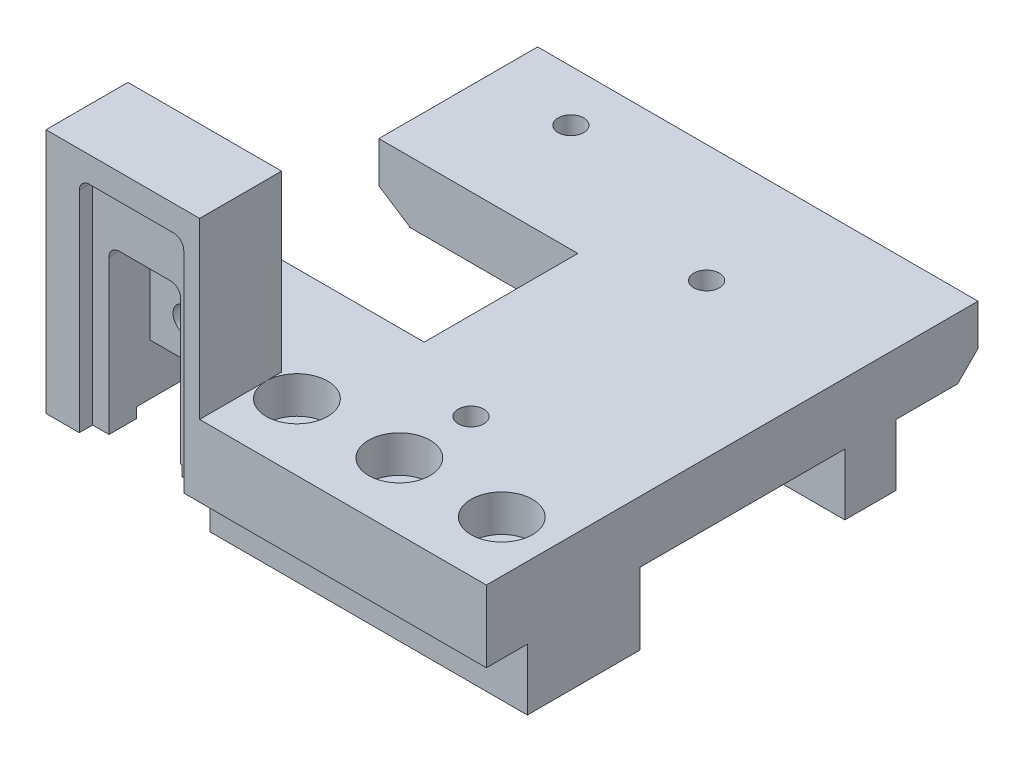
from build123d import *

# Parameters (mm, degrees)
SKETCH_1_W           = 50
SKETCH_1_H           = 13
EXTRUDE_1_DEPTH      = 48
SKETCH_9_R           = 1.6
CUT_EXTRUDE_7_DEPTH  = 14
SKETCH_10_R          = 3
CUT_EXTRUDE_10_DEPTH = 3.6
SKETCH_2_W           = 4
SKETCH_2_H           = 6
CUT_EXTRUDE_15_DEPTH = 51
SKETCH_18_W          = 20
SKETCH_18_H          = 7
CUT_EXTRUDE_16_DEPTH = 51
SKETCH_19_W          = 13
SKETCH_19_H          = 1
CUT_EXTRUDE_17_DEPTH = 51
SKETCH_21_W          = 8
SKETCH_21_H          = 6
CUT_EXTRUDE_19_DEPTH = 51
CHAMFER_1_SIZE       = 2
CUT_EXTRUDE_START    = 8
SKETCH_22_W          = 10
SKETCH_22_H          = 9
CUT_EXTRUDE_20_DEPTH = 49
CHAMFER_2_SIZE       = 3
CHAMFER_2_SIZE2      = 1.94822278
SKETCH_23_W          = 9
SKETCH_23_H          = 2.5
CUT_EXTRUDE_21_DEPTH = 41
SKETCH_26_W          = 7
SKETCH_26_H          = 4
CUT_EXTRUDE_24_DEPTH = 49
SKETCH_27_W          = 4
SKETCH_27_H          = 7
EXTRUDE_2_DEPTH      = 5
SKETCH_37_R          = 1.25
CUT_EXTRUDE_30_DEPTH = 5
SKETCH_38_W          = 15
SKETCH_38_H          = 8
EXTRUDE_3_DEPTH      = 17
SKETCH_39_W          = 10.2
SKETCH_39_H          = 21.5
CUT_EXTRUDE_31_DEPTH = 1.3
FILLET_2_R           = 1
SKETCH_40_R          = 1.25
CUT_EXTRUDE_32_DEPTH = 6
SKETCH_41_W          = 7
SKETCH_41_H          = 22
CUT_EXTRUDE_33_DEPTH = 4
SKETCH_43_W          = 7
SKETCH_43_H          = 12
CUT_EXTRUDE_35_DEPTH = 8
FILLET_3_R           = 1
SKETCH_44_W          = 19.428817274
SKETCH_44_H          = 15
CUT_EXTRUDE_37_DEPTH = 8
SKETCH_45_R          = 1.25
CUT_EXTRUDE_38_DEPTH = 5.5
SKETCH_46_W          = 45.087872193
SKETCH_46_H          = 5.805305433
CUT_EXTRUDE_39_DEPTH = 9


with BuildPart() as part:
    # Эскиз1 → Бобышка-Вытянуть1 (new body)
    with BuildSketch(Plane.XY):
        Rectangle(SKETCH_1_W, SKETCH_1_H)
    extrude(amount=EXTRUDE_1_DEPTH)

    # Эскиз9 → Вырез-Вытянуть7 (cut, through all)
    with BuildSketch(Plane(origin=(0, 6.5, 0), x_dir=(1, 0, 0), z_dir=(0, 1, 0))):
        with Locations(Location((20, -41.5, 0), (0, 0, 270))):  # turned: the seam where the file's is
            Circle(SKETCH_9_R)
        with Locations(Location((10, -41.5, 0), (0, 0, 270))):  # turned: the seam where the file's is
            Circle(SKETCH_9_R)
        with Locations(Location((0, -41.5, 0), (0, 0, 270))):  # turned: the seam where the file's is
            Circle(SKETCH_9_R)
    extrude(amount=-CUT_EXTRUDE_7_DEPTH, mode=Mode.SUBTRACT)

    # Эскиз10 → Вырез-Вытянуть10 (cut)
    with BuildSketch(Plane(origin=(0, 6.5, 0), x_dir=(1, 0, 0), z_dir=(0, 1, 0))):
        with Locations(Location((20, -41.5, 0), (0, 0, 270))):  # turned: the seam where the file's is
            Circle(SKETCH_10_R)
        with Locations(Location((10, -41.5, 0), (0, 0, 270))):  # turned: the seam where the file's is
            Circle(SKETCH_10_R)
        with Locations(Location((0, -41.5, 0), (0, 0, 270))):  # turned: the seam where the file's is
            Circle(SKETCH_10_R)
    extrude(amount=-CUT_EXTRUDE_10_DEPTH, mode=Mode.SUBTRACT)

    # Эскиз2 → Вырез-Вытянуть15 (cut, through all)
    with BuildSketch(Plane.ZY.offset(25)):
        with Locations((46, -3.5)):
            Rectangle(SKETCH_2_W, SKETCH_2_H)
    extrude(amount=-CUT_EXTRUDE_15_DEPTH, mode=Mode.SUBTRACT)

    # Эскиз18 → Вырез-Вытянуть16 (cut, through all)
    with BuildSketch(Plane.ZY.offset(25)):
        with Locations((23, -3)):
            Rectangle(SKETCH_18_W, SKETCH_18_H)
    extrude(amount=-CUT_EXTRUDE_16_DEPTH, mode=Mode.SUBTRACT)

    # Эскиз19 → Вырез-Вытянуть17 (cut, through all)
    with BuildSketch(Plane(origin=(25, 0, 0), x_dir=(0, 0, -1), z_dir=(1, 0, 0))):
        with Locations((-6.5, -6)):
            Rectangle(SKETCH_19_W, SKETCH_19_H)
    extrude(amount=-CUT_EXTRUDE_17_DEPTH, mode=Mode.SUBTRACT)

    # Эскиз21 → Вырез-Вытянуть19 (cut, through all)
    with BuildSketch(Plane(origin=(25, 0, 0), x_dir=(0, 0, -1), z_dir=(1, 0, 0))):
        with Locations((-4, -2.5)):
            Rectangle(SKETCH_21_W, SKETCH_21_H)
    extrude(amount=-CUT_EXTRUDE_19_DEPTH, mode=Mode.SUBTRACT)

    # Фаска1
    chamfer_1_edges = [part.edges().sort_by_distance(p)[0] for p in [
        (0, 0.5, 0),
    ]]
    chamfer(chamfer_1_edges, length=CHAMFER_1_SIZE)

    # Эскиз22 → Вырез-Вытянуть20 (cut, through all)
    with BuildSketch(Plane(origin=(0, 0, 8), x_dir=(-1, 0, 0), z_dir=(0, 0, -1)).offset(CUT_EXTRUDE_START)):
        with Locations((20, -2)):
            Rectangle(SKETCH_22_W, SKETCH_22_H)
    extrude(amount=-CUT_EXTRUDE_20_DEPTH, mode=Mode.SUBTRACT)

    # Фаска2
    chamfer_2_edges = [part.edges().sort_by_distance(p)[0] for p in [
        (-15, 2.5, 24),
    ]]
    chamfer_2_side = [part.faces().sort_by_distance(p)[0] for p in [
        (-20, 2.5, 24),
    ]]
    chamfer(chamfer_2_edges, length=CHAMFER_2_SIZE, length2=CHAMFER_2_SIZE2, reference=chamfer_2_side[0])

    # Эскиз23 → Вырез-Вытянуть21 (cut, through all)
    with BuildSketch(Plane(origin=(0, 0, 8), x_dir=(-1, 0, 0), z_dir=(0, 0, -1))):
        with Locations((10.5, -0.75)):
            Rectangle(SKETCH_23_W, SKETCH_23_H)
    extrude(amount=-CUT_EXTRUDE_21_DEPTH, mode=Mode.SUBTRACT)

    # Эскиз26 → Вырез-Вытянуть24 (cut, through all)
    with BuildSketch(Plane(origin=(0, 0, 0), x_dir=(-1, 0, 0), z_dir=(0, 0, -1))):
        with Locations((21.5, 4.5)):
            Rectangle(SKETCH_26_W, SKETCH_26_H)
    extrude(amount=-CUT_EXTRUDE_24_DEPTH, mode=Mode.SUBTRACT)

    # Эскиз27 → Бобышка-Вытянуть2 (add)
    with BuildSketch(Plane.ZY.offset(18)):
        with Locations((46, 3)):
            Rectangle(SKETCH_27_W, SKETCH_27_H)
    extrude(amount=-EXTRUDE_2_DEPTH)

    # Эскиз37 → Вырез-Вытянуть30 (cut)
    with BuildSketch(Plane(origin=(0, 6.5, 0), x_dir=(1, 0, 0), z_dir=(0, 1, 0))):
        with Locations(Location((10, -34.5, 0), (0, 0, 270))):  # turned: the seam where the file's is
            Circle(SKETCH_37_R)
        with Locations(Location((10, -11.5, 0), (0, 0, 270))):  # turned: the seam where the file's is
            Circle(SKETCH_37_R)
    extrude(amount=-CUT_EXTRUDE_30_DEPTH, mode=Mode.SUBTRACT)

    # Эскиз38 → Бобышка-Вытянуть3 (add)
    with BuildSketch(Plane(origin=(0, 6.5, 0), x_dir=(1, 0, 0), z_dir=(0, 1, 0))):
        with Locations((-10.5, -44)):
            Rectangle(SKETCH_38_W, SKETCH_38_H)
    extrude(amount=EXTRUDE_3_DEPTH)

    # Эскиз39 → Вырез-Вытянуть31 (cut)
    with BuildSketch(Plane.XY.offset(48)):
        with Locations((-9.65, 10.25)):
            Rectangle(SKETCH_39_W, SKETCH_39_H)
    extrude(amount=-CUT_EXTRUDE_31_DEPTH, mode=Mode.SUBTRACT)

    # Скругление2
    fillet_2_edges = [part.edges().sort_by_distance(p)[0] for p in [
        (-14.75, 21, 47.35),
        (-4.55, 21, 47.35),
    ]]
    fillet(fillet_2_edges, radius=FILLET_2_R)

    # Эскиз40 → Вырез-Вытянуть32 (cut)
    with BuildSketch(Plane.XY.offset(46.7)):
        with Locations((-9.65, 8.9)):
            Circle(SKETCH_40_R)
    extrude(amount=-CUT_EXTRUDE_32_DEPTH, mode=Mode.SUBTRACT)

    # Эскиз41 → Вырез-Вытянуть33 (cut)
    with BuildSketch(Plane.XY.offset(46.7)):
        with Locations((-9.65, 4.5)):
            Rectangle(SKETCH_41_W, SKETCH_41_H)
    extrude(amount=-CUT_EXTRUDE_33_DEPTH, mode=Mode.SUBTRACT)

    # Эскиз43 → Вырез-Вытянуть35 (cut)
    with BuildSketch(Plane.XY.offset(42.7)):
        with Locations((-9.65, -0.5)):
            Rectangle(SKETCH_43_W, SKETCH_43_H)
    extrude(amount=-CUT_EXTRUDE_35_DEPTH, mode=Mode.SUBTRACT)

    # Скругление3
    fillet_3_edges = [part.edges().sort_by_distance(p)[0] for p in [
        (-6.15, 15.5, 44.7),
        (-13.15, 15.5, 44.7),
    ]]
    fillet(fillet_3_edges, radius=FILLET_3_R)

    # Эскиз44 → Вырез-Вытянуть37 (cut)
    with BuildSketch(Plane(origin=(0, 6.5, 0), x_dir=(1, 0, 0), z_dir=(0, 1, 0))):
        with Locations((-8.285591363, -23)):
            Rectangle(SKETCH_44_W, SKETCH_44_H)
    extrude(amount=-CUT_EXTRUDE_37_DEPTH, mode=Mode.SUBTRACT)

    # Эскиз45 → Вырез-Вытянуть38 (cut)
    with BuildSketch(Plane(origin=(0, 6.5, 0), x_dir=(1, 0, 0), z_dir=(0, 1, 0))):
        with Locations(Location((-9.75, -5, 0), (0, 0, 270))):  # turned: the seam where the file's is
            Circle(SKETCH_45_R)
    extrude(amount=-CUT_EXTRUDE_38_DEPTH, mode=Mode.SUBTRACT)

    # Эскиз46 → Вырез-Вытянуть39 (cut)
    with BuildSketch(Plane.ZY.offset(15)):
        with Locations((23.854867364, -4.199105634)):
            Rectangle(SKETCH_46_W, SKETCH_46_H)
    extrude(amount=-CUT_EXTRUDE_39_DEPTH, mode=Mode.SUBTRACT)


solid = part.part
